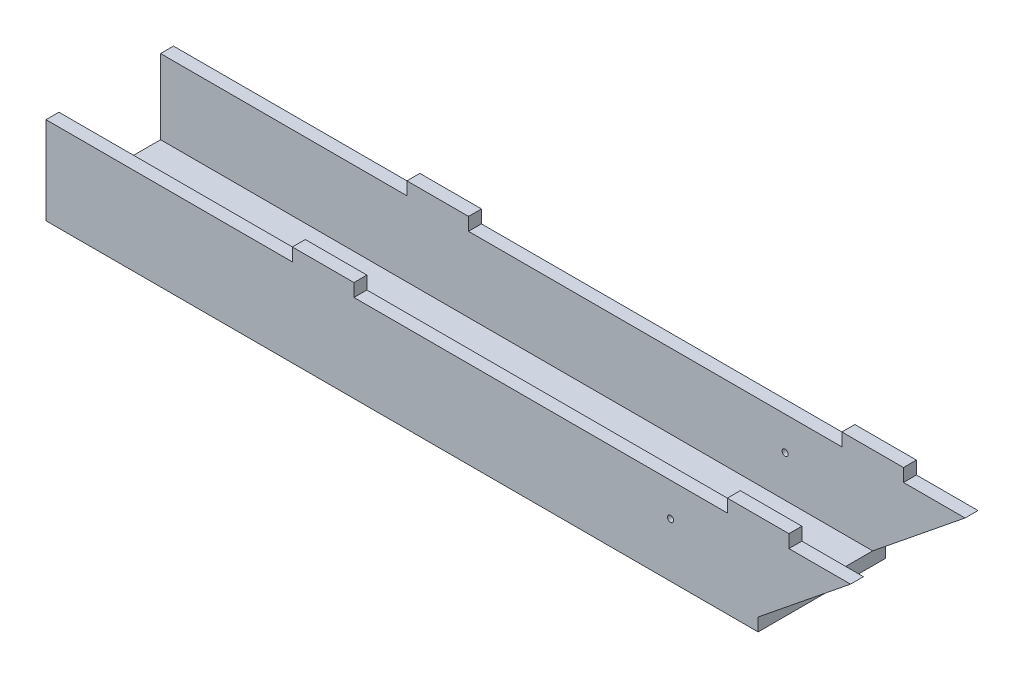
from build123d import *

# Parameters (mm, degrees)
SKETCH2_W              = 293.6875
SKETCH2_H              = 52.578
BOSS_EXTRUDE1_DEPTH    = 5.334
SKETCH3_W              = 25.4
SKETCH3_H              = 5.334
BOSS_EXTRUDE2_DEPTH    = 5.334
SKETCH4_R              = 1.27
BBQ_SKEWER_HOLES_DEPTH = 53.578


with BuildPart() as part:
    # Sketch2 → Boss-Extrude1 (new body)
    with BuildSketch(Plane(origin=(0, 0, 0), x_dir=(1, 0, 0), z_dir=(0, 1, 0))):
        Rectangle(SKETCH2_W, SKETCH2_H)
    extrude(amount=BOSS_EXTRUDE1_DEPTH)

    # Sketch3 → Boss-Extrude2 (add)
    with BuildSketch(Plane.XY.offset(26.289)):
        Polygon((184.94375, 36.1188), (146.84375, 5.334), (-146.84375, 5.334), (-146.84375, 36.1188), (146.84375, 36.1188), align=None)
        with Locations((-32.54375, 38.7858)):
            Rectangle(SKETCH3_W, SKETCH3_H)
        Polygon((146.84375, 36.1188), (159.54375, 36.1188), (159.54375, 41.4528), (134.14375, 41.4528), (134.14375, 36.1188), align=None)
    boss_extrude2 = extrude(amount=-BOSS_EXTRUDE2_DEPTH)

    # Mirror1: Boss-Extrude2 across plane
    add(boss_extrude2.mirror(Plane.XY))

    # Sketch4 → BBQ Skewer Holes (cut, through all)
    with BuildSketch(Plane.XY.offset(26.289)):
        with Locations((110.744734301, 22.342412484)):
            Circle(SKETCH4_R)
    extrude(amount=-BBQ_SKEWER_HOLES_DEPTH, mode=Mode.SUBTRACT)


solid = part.part
